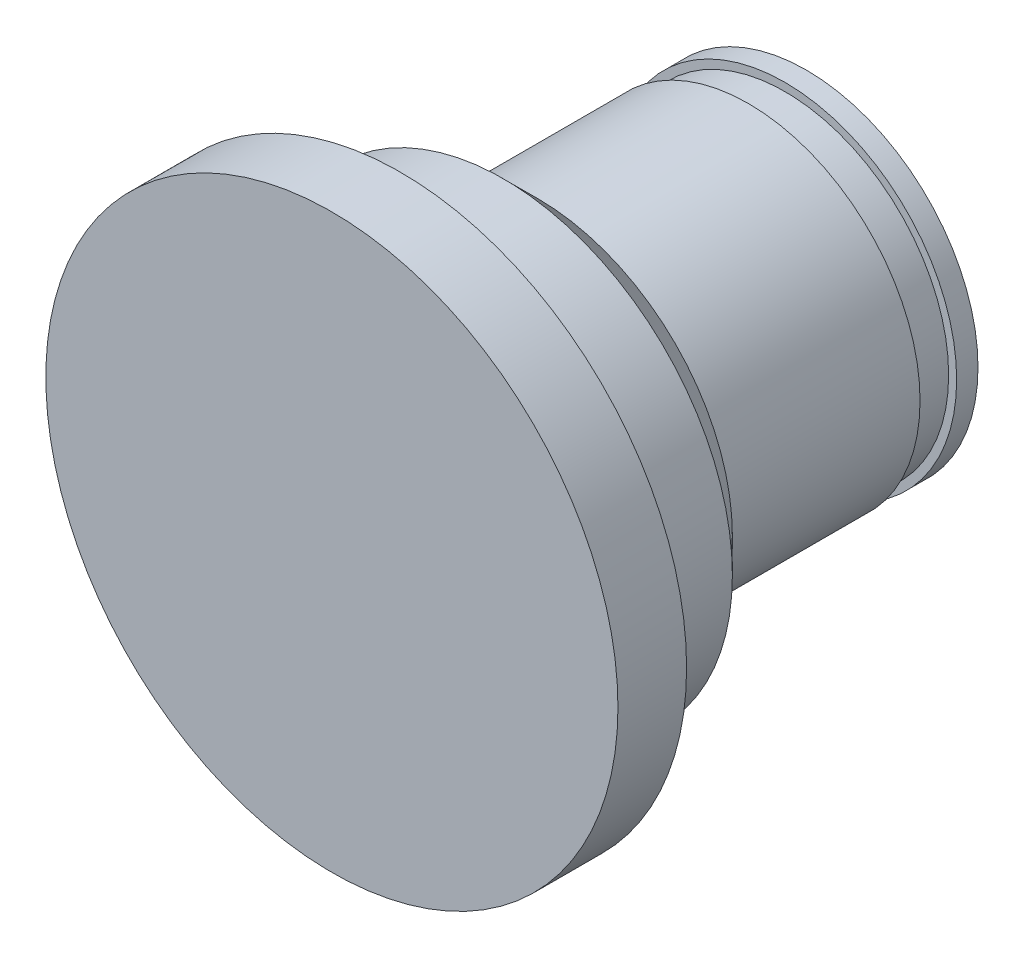
from build123d import *

# Parameters (mm, degrees)
CHAMFER1_SIZE  = 1
CHAMFER1_SIZE2 = 0.267949192
CHAMFER2_SIZE  = 1.5


with BuildPart() as part:
    # Sketch1 → Revolve1 (revolve)
    with BuildSketch(Plane(origin=(0, 0, 0), x_dir=(1, 0, 0), z_dir=(0, 1, 0))):
        Polygon((0, 0), (12.5, 0), (12.5, 3), (10, 3), (10, 9), (7.5, 9), (7.5, 18.2), (7.15, 18.2), (7.15, 19.8), (7.5, 19.8), (7.5, 21), (0, 21), align=None)
    revolve(axis=Axis((0, 0, 0), (0, 0, -1)))

    # Chamfer1
    chamfer1_edges = [part.edges().sort_by_distance(p)[0] for p in [
        (-7.5, 0, -21),
    ]]
    chamfer1_side = [part.faces().sort_by_distance(p)[0] for p in [
        (0, 0, -21),
    ]]
    chamfer(chamfer1_edges, length=CHAMFER1_SIZE, length2=CHAMFER1_SIZE2, reference=chamfer1_side[0])

    # Chamfer2
    chamfer2_edges = [part.edges().sort_by_distance(p)[0] for p in [
        (-10, 0, -9),
    ]]
    chamfer(chamfer2_edges, length=CHAMFER2_SIZE)


solid = part.part
